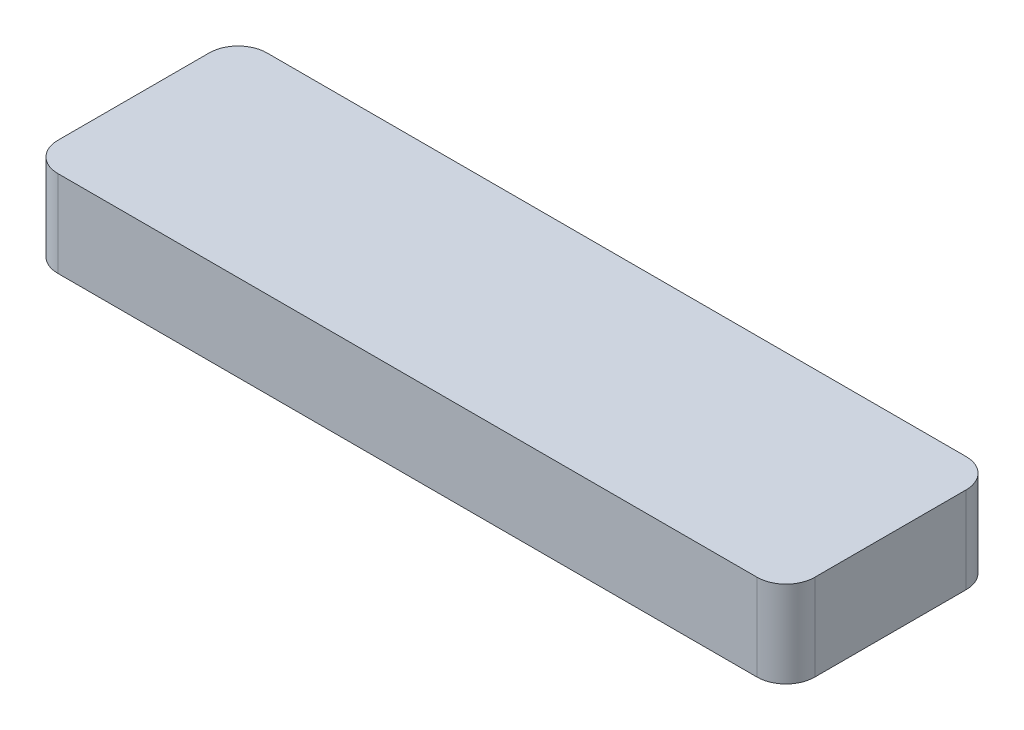
from build123d import *

# Parameters (mm, degrees)
EXTRUSION1_DEPTH        = 6
ESQUISSE7_W             = 30
ESQUISSE7_H             = 1
ENL_V_MAT_EXTRU_1_DEPTH = 6


with BuildPart() as part:
    # Esquisse1 → Extrusion1 (new body)
    with BuildSketch(Plane(origin=(0, 0, 0), x_dir=(1, 0, 0), z_dir=(0, 1, 0))):
        with BuildLine():
            Line((-24.25, -7.25), (24.25, -7.25))
            ThreePointArc((24.25, -7.25), (25.664213562, -6.664213562), (26.25, -5.25))
            Line((26.25, -5.25), (26.25, 5.25))
            ThreePointArc((26.25, 5.25), (25.664213562, 6.664213562), (24.25, 7.25))
            Line((24.25, 7.25), (-24.25, 7.25))
            ThreePointArc((-24.25, 7.25), (-25.664213562, 6.664213562), (-26.25, 5.25))
            Line((-26.25, 5.25), (-26.25, -5.25))
            ThreePointArc((-26.25, -5.25), (-25.664213562, -6.664213562), (-24.25, -7.25))
        make_face()
    extrude(amount=EXTRUSION1_DEPTH)

    # Esquisse6 → Révolution1 (revolve)
    with BuildSketch(Plane.XY):
        Polygon((-12, 0), (-12, -5), (-13.75, -5), (-15, -3.5), (-14.5, -3.5), (-14.5, 0), align=None)
    r_volution1 = revolve(axis=Axis((-12, 10.671623644, 0), (0, -1, 0)))

    # Symétrie1: Révolution1 across plane
    add(r_volution1.mirror(Plane(origin=(0, 0, 0), x_dir=(0, 0, 1), z_dir=(1, 0, 0))))

    # Esquisse7 → Enlèv. mat.-Extru.1 (cut, through all)
    with BuildSketch(Plane.XZ):
        Rectangle(ESQUISSE7_W, ESQUISSE7_H)
    extrude(amount=ENL_V_MAT_EXTRU_1_DEPTH, mode=Mode.SUBTRACT)


solid = part.part
